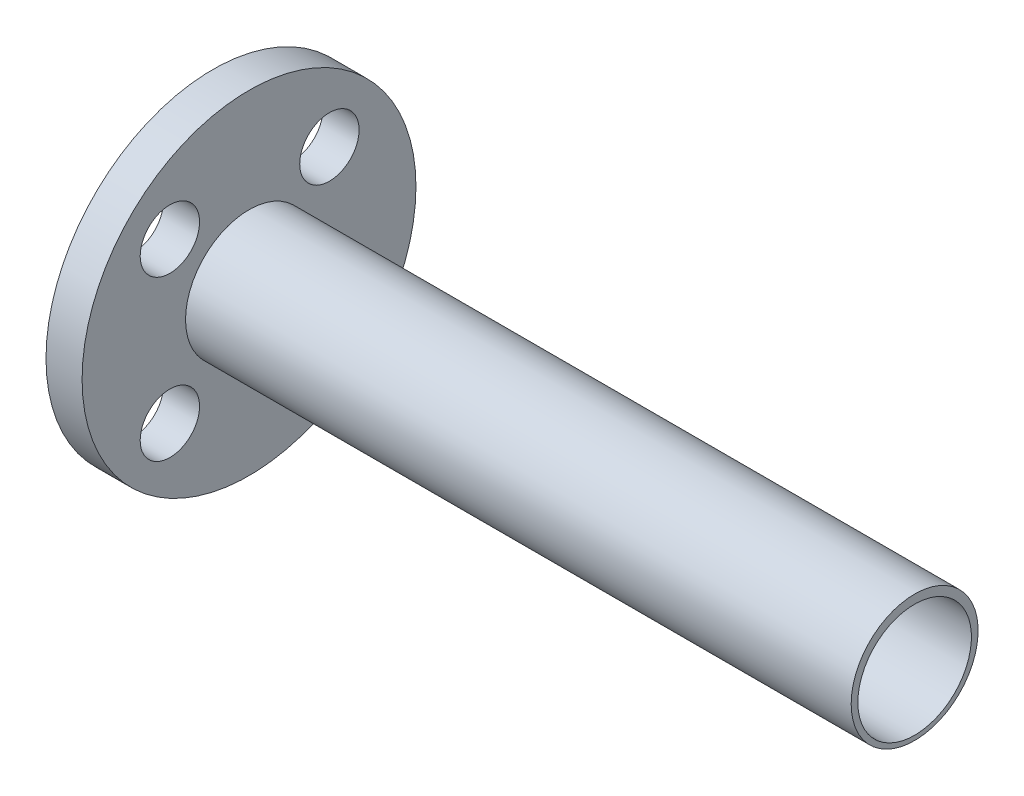
from build123d import *

# Parameters (mm, degrees)
SKETCH3_R          = 15.18
CUT_EXTRUDE1_DEPTH = 187.086523502
SKETCH5_R          = 7.9375
CUT_EXTRUDE2_DEPTH = 10


with BuildPart() as part:
    # Sketch1 → Revolve1 (revolve)
    with BuildSketch(Plane.XY):
        Polygon((53.975, 0.555053367), (53.975, 11.176), (53.975, 17.526), (52.451, 17.526), (52.451, 45.185378607), (62.101, 45.185378607), (62.101, 17.526), (240.061523502, 17.526), (240.061523502, 0.555053367), align=None)
    revolve(axis=Axis((53.975, 0.555053367, 0), (1, 0, 0)))

    # Sketch3 → Cut-Extrude1 (cut, through all)
    with BuildSketch(Plane.ZY.offset(-53.975)):
        Circle(SKETCH3_R)
    extrude(amount=-CUT_EXTRUDE1_DEPTH, mode=Mode.SUBTRACT)

    # Sketch5 → Cut-Extrude2 (cut)
    with BuildSketch(Plane.ZY.offset(-52.451)):
        with Locations((-21.49441643, 21.314234902)):
            Circle(SKETCH5_R)
        with Locations((-21.49441643, -21.341981673)):
            Circle(SKETCH5_R)
        with Locations((21.161800145, 21.314234902)):
            Circle(SKETCH5_R)
        with Locations((21.161800145, -21.341981673)):
            Circle(SKETCH5_R)
    extrude(amount=-CUT_EXTRUDE2_DEPTH, mode=Mode.SUBTRACT)


solid = part.part
